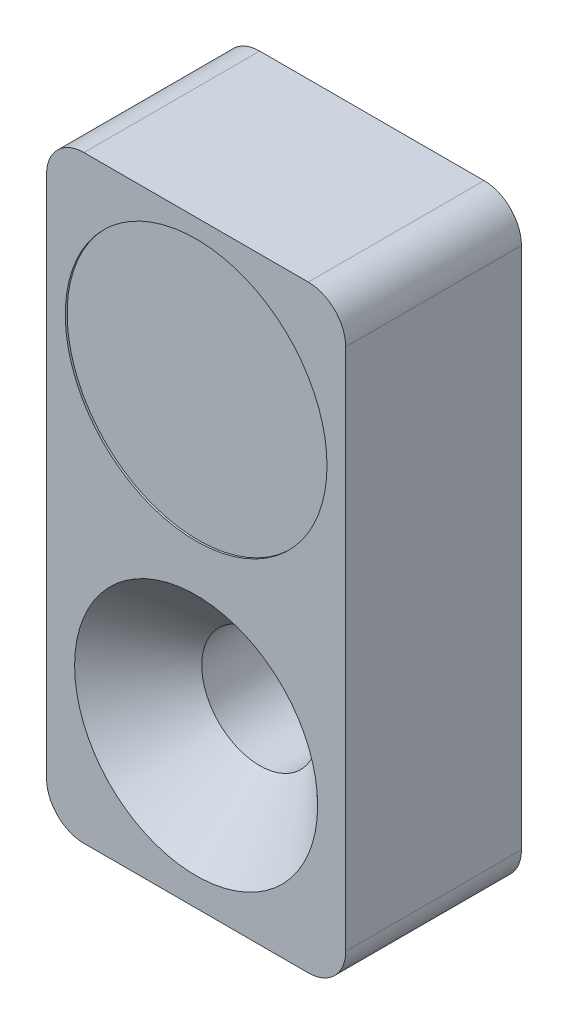
from build123d import *

# Parameters (mm, degrees)
SKIZZE1_W                       = 8
SKIZZE1_H                       = 16
AUFSATZ_LINEAR_AUSTRAGEN1_DEPTH = 4.7
VERRUNDUNG1_R                   = 1
SKIZZE2_R                       = 3.5
SCHNITT_LINEAR_AUSTRAGEN1_DEPTH = 0.05


with BuildPart() as part:
    # Skizze1 → Aufsatz-Linear austragen1 (new body)
    with BuildSketch(Plane.XY):
        with Locations((4, -8)):
            Rectangle(SKIZZE1_W, SKIZZE1_H)
    extrude(amount=AUFSATZ_LINEAR_AUSTRAGEN1_DEPTH)

    # Verrundung1
    verrundung1_edges = [part.edges().sort_by_distance(p)[0] for p in [
        (0, 0, 2.35),
        (8, 0, 2.35),
        (8, -16, 2.35),
        (0, -16, 2.35),
    ]]
    fillet(verrundung1_edges, radius=VERRUNDUNG1_R)

    # Skizze2 → Schnitt-Linear austragen1 (cut)
    with BuildSketch(Plane.XY.offset(4.7)):
        with Locations((4, -4)):
            Circle(SKIZZE2_R)
    extrude(amount=-SCHNITT_LINEAR_AUSTRAGEN1_DEPTH, mode=Mode.SUBTRACT)

    # Skizze3 → Schnitt-Rotation1 (revolve, cut)
    with BuildSketch(Plane(origin=(4, 0, 0), x_dir=(0, 0, -1), z_dir=(1, 0, 0))):
        Polygon((-4.7, -8.75), (-3, -10.45), (0, -10.45), (0, -12), (-4.7, -12), align=None)
    revolve(axis=Axis((4, -12, 4.7), (0, 0, -1)), mode=Mode.SUBTRACT)


solid = part.part
